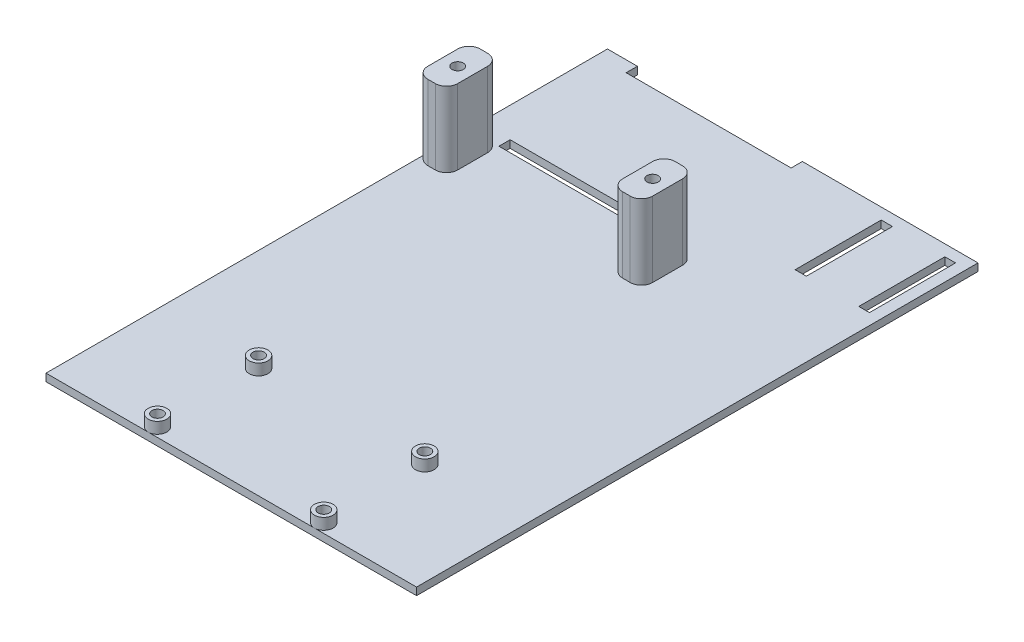
from build123d import *

# Parameters (mm, degrees)
SKETCH1_W           = 99
SKETCH1_H           = 150
BOSS_EXTRUDE1_DEPTH = 2
SKETCH2_W           = 8
SKETCH2_H           = 14
BOSS_EXTRUDE2_DEPTH = 20
SKETCH3_R           = 1.5
CUT_EXTRUDE2_DEPTH  = 15
FILLET1_R           = 3
FILLET2_R           = 3
FILLET5_R           = 3
FILLET6_R           = 3
FILLET7_R           = 3
FILLET8_R           = 3
FILLET9_R           = 3
FILLET10_R          = 3
SKETCH5_W           = 44.075
SKETCH5_H           = 3
SKETCH5_W_2         = 2.852474079
SKETCH5_H_2         = 23
SKETCH5_W_3         = 3
CUT_EXTRUDE3_DEPTH  = 10
BOSS_EXTRUDE3_DEPTH = 3


with BuildPart() as part:
    # Sketch1 → Boss-Extrude1 (new body)
    with BuildSketch(Plane(origin=(0, 0, 0), x_dir=(1, 0, 0), z_dir=(0, 1, 0))):
        with Locations((49.5, 75)):
            Rectangle(SKETCH1_W, SKETCH1_H)
    extrude(amount=BOSS_EXTRUDE1_DEPTH)

    # Sketch2 → Boss-Extrude2 (add)
    with BuildSketch(Plane(origin=(0, 2, 0), x_dir=(1, 0, 0), z_dir=(0, 1, 0))):
        with Locations((4, 106)):
            Rectangle(SKETCH2_W, SKETCH2_H)
        with Locations((56.075, 106)):
            Rectangle(SKETCH2_W, SKETCH2_H)
    extrude(amount=BOSS_EXTRUDE2_DEPTH)

    # Sketch3 → Cut-Extrude2 (cut)
    with BuildSketch(Plane(origin=(0, 22, 0), x_dir=(1, 0, 0), z_dir=(0, 1, 0))):
        with Locations((56.075, 106)):
            Circle(SKETCH3_R)
        with Locations((4, 106)):
            Circle(SKETCH3_R)
    extrude(amount=-CUT_EXTRUDE2_DEPTH, mode=Mode.SUBTRACT)

    # Fillet1
    fillet1_edges = [part.edges().sort_by_distance(p)[0] for p in [
        (0, 12, -99),
    ]]
    fillet(fillet1_edges, radius=FILLET1_R)

    # Fillet2
    fillet2_edges = [part.edges().sort_by_distance(p)[0] for p in [
        (0, 12, -113),
    ]]
    fillet(fillet2_edges, radius=FILLET2_R)

    # Fillet5
    fillet5_edges = [part.edges().sort_by_distance(p)[0] for p in [
        (8, 12, -113),
    ]]
    fillet(fillet5_edges, radius=FILLET5_R)

    # Fillet6
    fillet6_edges = [part.edges().sort_by_distance(p)[0] for p in [
        (8, 12, -99),
    ]]
    fillet(fillet6_edges, radius=FILLET6_R)

    # Fillet7
    fillet7_edges = [part.edges().sort_by_distance(p)[0] for p in [
        (60.075, 12, -99),
    ]]
    fillet(fillet7_edges, radius=FILLET7_R)

    # Fillet8
    fillet8_edges = [part.edges().sort_by_distance(p)[0] for p in [
        (60.075, 12, -113),
    ]]
    fillet(fillet8_edges, radius=FILLET8_R)

    # Fillet9
    fillet9_edges = [part.edges().sort_by_distance(p)[0] for p in [
        (52.075, 12, -113),
    ]]
    fillet(fillet9_edges, radius=FILLET9_R)

    # Fillet10
    fillet10_edges = [part.edges().sort_by_distance(p)[0] for p in [
        (52.075, 12, -99),
    ]]
    fillet(fillet10_edges, radius=FILLET10_R)

    # Sketch5 → Cut-Extrude3 (cut)
    with BuildSketch(Plane(origin=(0, 2, 0), x_dir=(1, 0, 0), z_dir=(0, 1, 0))):
        with Locations((30.0375, 148.5)):
            Rectangle(SKETCH5_W, SKETCH5_H)
        with Locations((30.0375, 114.5)):
            Rectangle(SKETCH5_W, SKETCH5_H)
        with Locations((94.573762961, 135.5)):
            Rectangle(SKETCH5_W_2, SKETCH5_H_2)
        with Locations((77.647525921, 135.5)):
            Rectangle(SKETCH5_W_3, SKETCH5_H_2)
    extrude(amount=-CUT_EXTRUDE3_DEPTH, mode=Mode.SUBTRACT)

    # Sketch6 → Boss-Extrude3 (add)
    with BuildSketch(Plane(origin=(0, 2, 0), x_dir=(1, 0, 0), z_dir=(0, 1, 0))):
        with BuildLine():
            ThreePointArc((29.79, 29.5), (25.522233047, 31.267766953), (27.29, 27))
            Line((27.29, 27), (27.29, 28))
            ThreePointArc((27.29, 28), (26.229339828, 30.560660172), (28.79, 29.5))
            Line((28.79, 29.5), (29.79, 29.5))
        make_face()
        with BuildLine():
            Line((27.29, 28), (27.29, 27))
            ThreePointArc((27.29, 27), (29.057766953, 27.732233047), (29.79, 29.5))
            Line((29.79, 29.5), (28.79, 29.5))
            ThreePointArc((28.79, 29.5), (28.350660172, 28.439339828), (27.29, 28))
        make_face()
        with BuildLine():
            ThreePointArc((69.21, 29.5), (69.942233047, 27.732233047), (71.71, 27))
            Line((71.71, 27), (71.71, 28))
            ThreePointArc((71.71, 28), (70.649339828, 28.439339828), (70.21, 29.5))
            Line((70.21, 29.5), (69.21, 29.5))
        make_face()
        with BuildLine():
            Line((71.71, 28), (71.71, 27))
            ThreePointArc((71.71, 27), (73.477766953, 27.732233047), (74.21, 29.5))
            ThreePointArc((74.21, 29.5), (71.71, 32), (69.21, 29.5))
            Line((69.21, 29.5), (70.21, 29.5))
            ThreePointArc((70.21, 29.5), (71.71, 31), (73.21, 29.5))
            ThreePointArc((73.21, 29.5), (72.770660172, 28.439339828), (71.71, 28))
        make_face()
        with BuildLine():
            ThreePointArc((27.29, 5), (25.522233047, 0.732233047), (29.79, 2.5))
            Line((29.79, 2.5), (28.79, 2.5))
            ThreePointArc((28.79, 2.5), (26.229339828, 1.439339828), (27.29, 4))
            Line((27.29, 4), (27.29, 5))
        make_face()
        with BuildLine():
            Line((28.79, 2.5), (29.79, 2.5))
            ThreePointArc((29.79, 2.5), (29.057766953, 4.267766953), (27.29, 5))
            Line((27.29, 5), (27.29, 4))
            ThreePointArc((27.29, 4), (28.350660172, 3.560660172), (28.79, 2.5))
        make_face()
        with BuildLine():
            ThreePointArc((71.71, 5), (69.942233047, 4.267766953), (69.21, 2.5))
            Line((69.21, 2.5), (70.21, 2.5))
            ThreePointArc((70.21, 2.5), (70.649339828, 3.560660172), (71.71, 4))
            Line((71.71, 4), (71.71, 5))
        make_face()
        with BuildLine():
            Line((70.21, 2.5), (69.21, 2.5))
            ThreePointArc((69.21, 2.5), (71.71, 0), (74.21, 2.5))
            ThreePointArc((74.21, 2.5), (73.477766953, 4.267766953), (71.71, 5))
            Line((71.71, 5), (71.71, 4))
            ThreePointArc((71.71, 4), (72.770660172, 3.560660172), (73.21, 2.5))
            ThreePointArc((73.21, 2.5), (71.71, 1), (70.21, 2.5))
        make_face()
    extrude(amount=BOSS_EXTRUDE3_DEPTH)


solid = part.part
